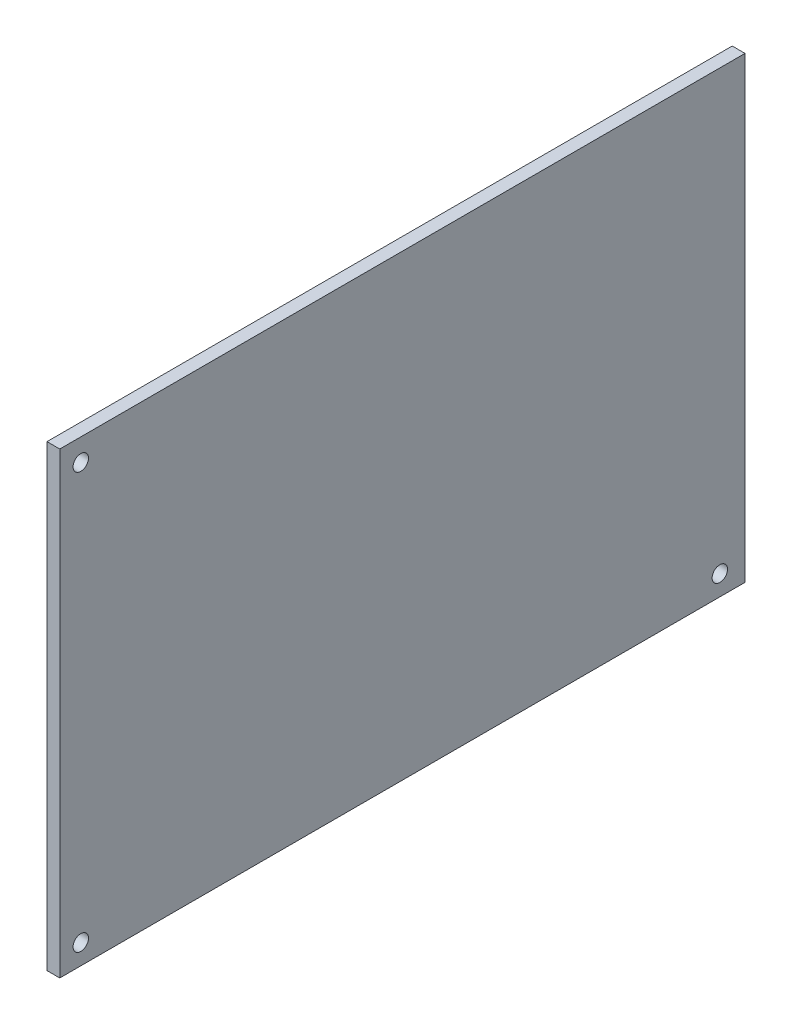
from build123d import *

# Parameters (mm, degrees)
ESBO_O1_W                = 89
ESBO_O1_H                = 59.5
RESSALTO_EXTRUS_O1_DEPTH = 1.66
ESBO_O2_R                = 1
CORTE_EXTRUS_O1_DEPTH    = 2.66


with BuildPart() as part:
    # Esboço1 → Ressalto-extrusão1 (new body)
    with BuildSketch(Plane(origin=(0, 0, 0), x_dir=(0, 0, -1), z_dir=(1, 0, 0))):
        with Locations((44.5, 29.75)):
            Rectangle(ESBO_O1_W, ESBO_O1_H)
    extrude(amount=RESSALTO_EXTRUS_O1_DEPTH)

    # Esboço2 → Corte-extrusão1 (cut, through all)
    with BuildSketch(Plane.ZY):
        with Locations((-85.731930575, 2.62372378)):
            Circle(ESBO_O2_R)
        with Locations((-2.731930575, 2.62372378)):
            Circle(ESBO_O2_R)
        with Locations((-2.731930575, 56.62372378)):
            Circle(ESBO_O2_R)
    extrude(amount=-CORTE_EXTRUS_O1_DEPTH, mode=Mode.SUBTRACT)


solid = part.part
